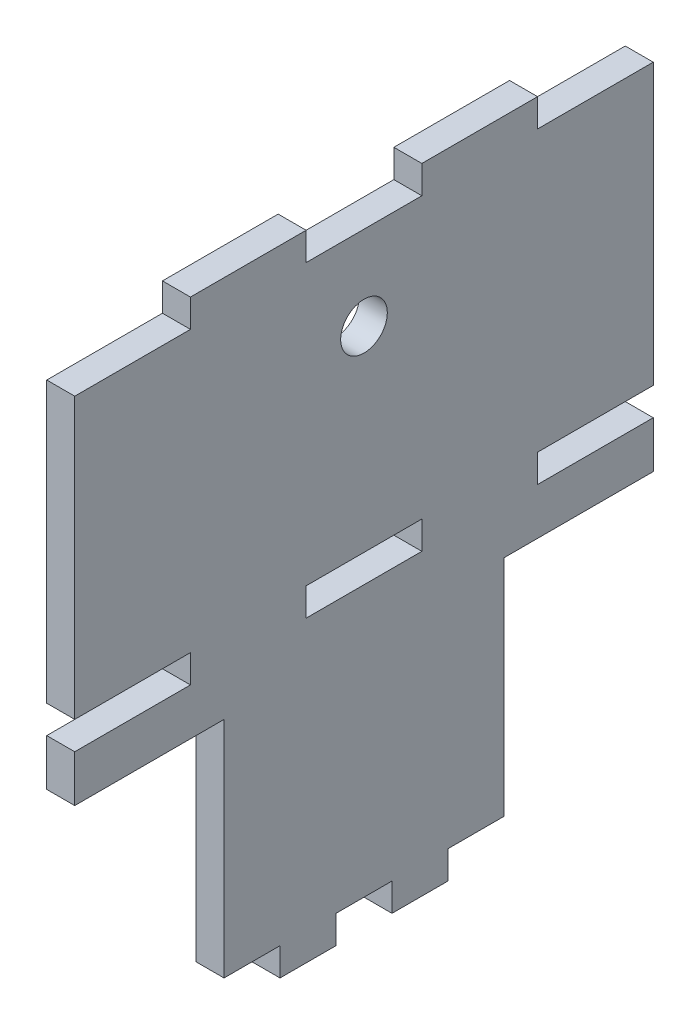
from build123d import *

# Parameters (mm, degrees)
SKETCH1_R           = 2.5
SKETCH1_W           = 12.4
SKETCH1_H           = 3
BOSS_EXTRUDE3_DEPTH = 3


with BuildPart() as part:
    # Sketch1 → Boss-Extrude3 (new body)
    with BuildSketch(Plane(origin=(0, 0, 0), x_dir=(0, 0, -1), z_dir=(1, 0, 0))):
        Polygon((31, -2), (31, -7), (15, -7), (15, -31), (9, -31), (9, -34), (3, -34), (3, -31), (-3, -31), (-3, -34), (-9, -34), (-9, -31), (-15, -31), (-15, -7), (-31, -7), (-31, -2), (-18.6, -2), (-18.6, 1), (-31, 1), (-31, 31), (-18.6, 31), (-18.6, 34), (-6.2, 34), (-6.2, 31), (6.2, 31), (6.2, 34), (18.6, 34), (18.6, 31), (31, 31), (31, 1), (18.6, 1), (18.6, -2), align=None)
        with Locations((0, 22)):
            Circle(SKETCH1_R, mode=Mode.SUBTRACT)
        with Locations((0, -0.5)):
            Rectangle(SKETCH1_W, SKETCH1_H, mode=Mode.SUBTRACT)
    extrude(amount=BOSS_EXTRUDE3_DEPTH)


solid = part.part
